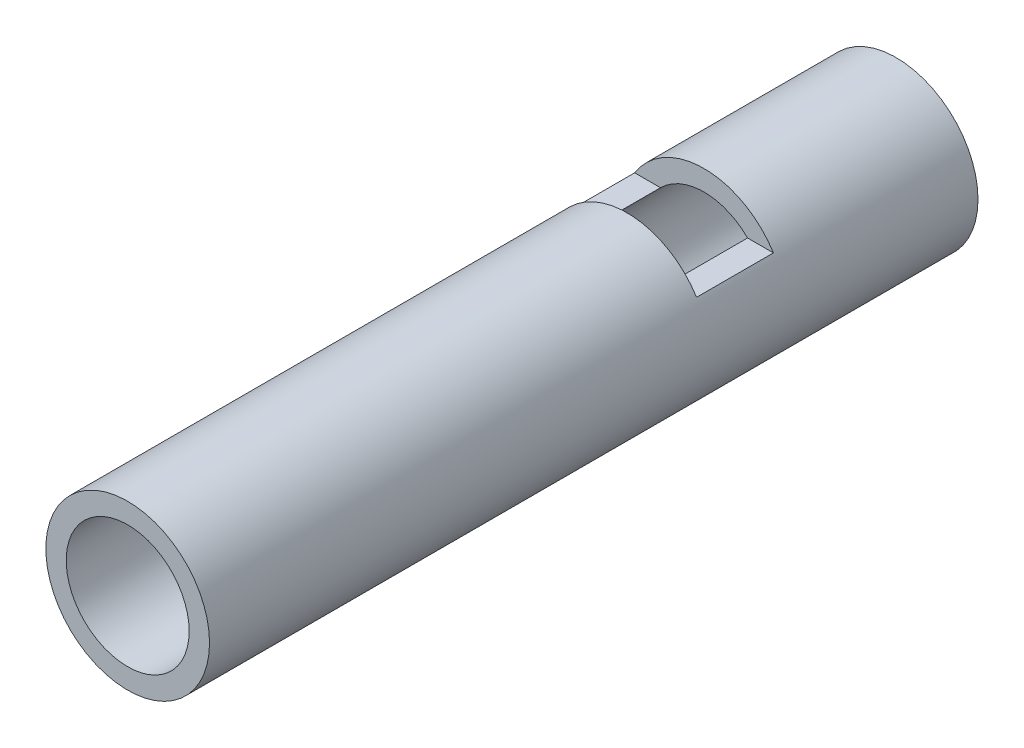
from build123d import *

# Parameters (mm, degrees)
SKIZZE1_R                            = 10.65
SKIZZE1_R_2                          = 8
AUFSATZ_LINEAR_AUSTRAGEN1_DEPTH      = 100
SCHNITT_LINEAR_AUSTRAGEN1_DEPTH      = 10
SCHNITT_LINEAR_AUSTRAGEN1_DEPTH_BACK = 10
SKIZZE2_W                            = 10
SKIZZE2_H                            = 5


with BuildPart() as part:
    # Skizze1 → Aufsatz-Linear austragen1 (new body)
    with BuildSketch(Plane.XY):
        Circle(SKIZZE1_R)
        Circle(SKIZZE1_R_2, mode=Mode.SUBTRACT)
    extrude(amount=AUFSATZ_LINEAR_AUSTRAGEN1_DEPTH)

    # Skizze2 → Schnitt-Linear austragen1 (cut, two sides: drawn at the far end of the back side and taken through both)
    with BuildSketch(Plane(origin=(0, 0, 0), x_dir=(0, 0, -1), z_dir=(1, 0, 0)).offset(-SCHNITT_LINEAR_AUSTRAGEN1_DEPTH_BACK)):
        with Locations((-30, 8.15)):
            Rectangle(SKIZZE2_W, SKIZZE2_H)
    extrude(amount=SCHNITT_LINEAR_AUSTRAGEN1_DEPTH + SCHNITT_LINEAR_AUSTRAGEN1_DEPTH_BACK, mode=Mode.SUBTRACT)


solid = part.part
